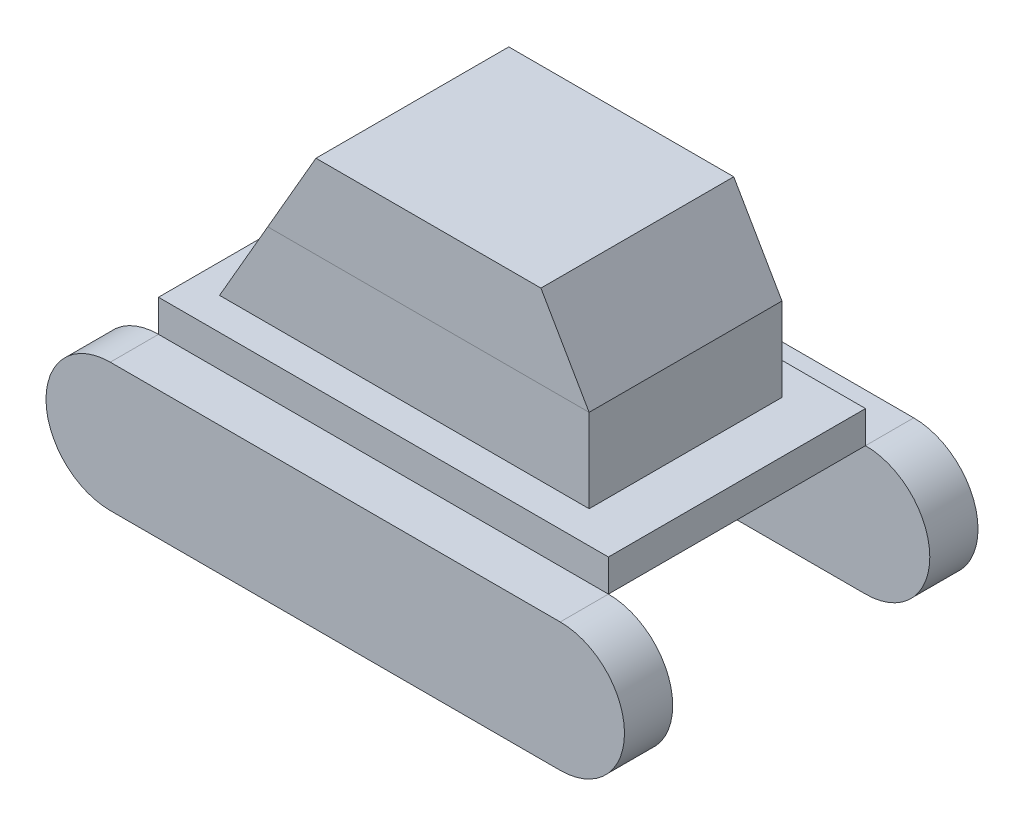
from build123d import *

# Parameters (mm, degrees)
BOSS_EXTRUDE1_DEPTH = 15
SKETCH2_W           = 140
SKETCH2_H           = 80
BOSS_EXTRUDE2_DEPTH = 10
BOSS_EXTRUDE3_DEPTH = 60
BOSS_EXTRUDE4_DEPTH = 15


with BuildPart() as part:
    # Sketch1 → Boss-Extrude1 (new body)
    with BuildSketch(Plane.XY):
        with BuildLine():
            Line((0, 40), (140, 40))
            ThreePointArc((140, 40), (160, 20), (140, 0))
            Line((140, 0), (0, 0))
            ThreePointArc((0, 0), (-20, 20), (0, 40))
        make_face()
    extrude(amount=BOSS_EXTRUDE1_DEPTH)


with BuildPart() as body_2:
    # Sketch2 → Boss-Extrude2 (new body)
    with BuildSketch(Plane(origin=(0, 40, 0), x_dir=(1, 0, 0), z_dir=(0, 1, 0))):
        with Locations((70, -55)):
            Rectangle(SKETCH2_W, SKETCH2_H)
    extrude(amount=BOSS_EXTRUDE2_DEPTH)

    # Sketch3 → Boss-Extrude3 (add)
    with BuildSketch(Plane(origin=(0, 0, 25), x_dir=(-1, 0, 0), z_dir=(0, 0, -1))):
        Polygon((-9, 50), (-39, 101.961524227), (-109, 101.961524227), (-124, 75.980762114), (-124, 50), align=None)
    extrude(amount=-BOSS_EXTRUDE3_DEPTH)


with BuildPart() as body_3:
    # Sketch4 → Boss-Extrude4 (new body)
    with BuildSketch(Plane.XY.offset(95)):
        with BuildLine():
            Line((0, 40), (140, 40))
            ThreePointArc((140, 40), (160, 20), (140, 0))
            Line((140, 0), (0, 0))
            ThreePointArc((0, 0), (-20, 20), (0, 40))
        make_face()
    extrude(amount=BOSS_EXTRUDE4_DEPTH)


solid = Compound([part.part, body_2.part, body_3.part])
